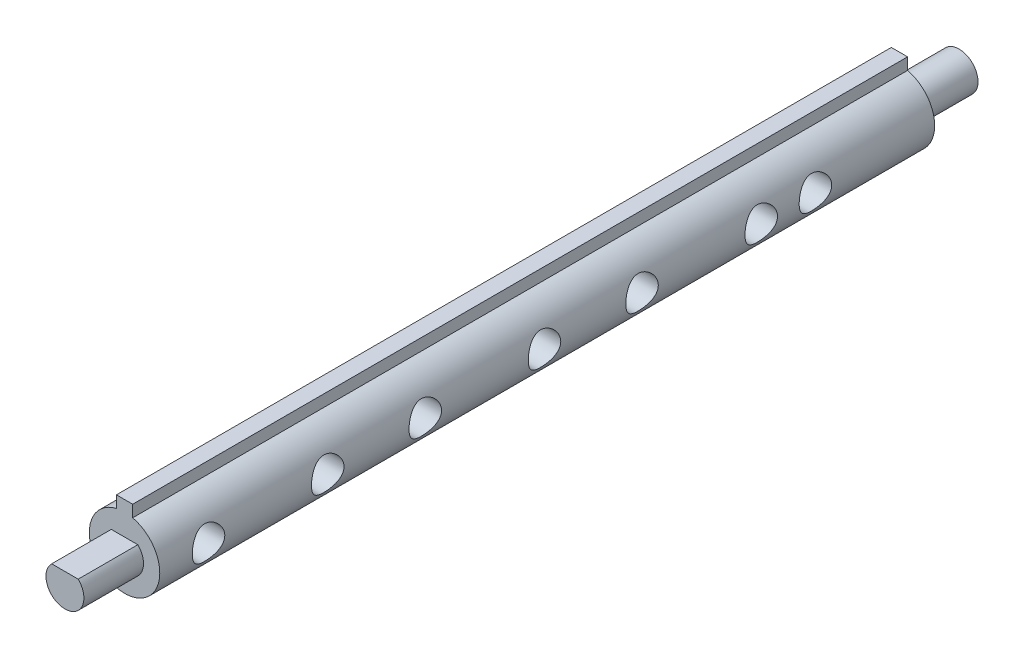
from build123d import *

# Parameters (mm, degrees)
EXTRUDE_1_DEPTH     = 143
SKETCH_2_R          = 3.5
EXTRUDE_2_DEPTH     = 11
SKETCH_3_R          = 3.5
EXTRUDE_3_DEPTH     = 11
CUT_EXTRUDE_1_DEPTH = 11
CUT_EXTRUDE_2_DEPTH = 11
SKETCH_7_R          = 3
CUT_EXTRUDE_3_DEPTH = 10


with BuildPart() as part:
    # 草图1 → 凸台-拉伸1 (new body)
    with BuildSketch(Plane.XY):
        with BuildLine():
            Line((-1.5, 6.32455532), (-1.5, 8.5))
            Line((-1.5, 8.5), (1.5, 8.5))
            Line((1.5, 8.5), (1.5, 6.32455532))
            ThreePointArc((1.5, 6.32455532), (0, -6.5), (-1.5, 6.32455532))
        make_face()
    extrude(amount=EXTRUDE_1_DEPTH)

    # 草图2 → 凸台-拉伸2 (add)
    with BuildSketch(Plane.XY.offset(143)):
        Circle(SKETCH_2_R)
    extrude(amount=EXTRUDE_2_DEPTH)

    # 草图3 → 凸台-拉伸3 (add)
    with BuildSketch(Plane(origin=(0, 0, 0), x_dir=(-1, 0, 0), z_dir=(0, 0, -1))):
        Circle(SKETCH_3_R)
    extrude(amount=EXTRUDE_3_DEPTH)

    # 草图4 → 切除-拉伸1 (cut)
    with BuildSketch(Plane(origin=(0, 0, -11), x_dir=(-1, 0, 0), z_dir=(0, 0, -1))):
        with BuildLine():
            Line((-2.449489743, -2.5), (2.449489743, -2.5))
            ThreePointArc((2.449489743, -2.5), (0, -3.5), (-2.449489743, -2.5))
        make_face()
    extrude(amount=-CUT_EXTRUDE_1_DEPTH, mode=Mode.SUBTRACT)

    # 草图5 → 切除-拉伸2 (cut)
    with BuildSketch(Plane.XY.offset(154)):
        with BuildLine():
            Line((-2.449489743, 2.5), (2.449489743, 2.5))
            ThreePointArc((2.449489743, 2.5), (0, 3.5), (-2.449489743, 2.5))
        make_face()
    extrude(amount=-CUT_EXTRUDE_2_DEPTH, mode=Mode.SUBTRACT)

    # 草图7 → 切除-拉伸3 (cut, symmetric)
    with BuildSketch(Plane(origin=(0, 0, 0), x_dir=(0, 0, -1), z_dir=(1, 0, 0))):
        with Locations((-134, 0)):
            Circle(SKETCH_7_R)
        with Locations((-112, 0)):
            Circle(SKETCH_7_R)
        with Locations((-94, 0)):
            Circle(SKETCH_7_R)
        with Locations((-72, 0)):
            Circle(SKETCH_7_R)
        with Locations((-54, 0)):
            Circle(SKETCH_7_R)
        with Locations((-32, 0)):
            Circle(SKETCH_7_R)
        with Locations((-22, 0)):
            Circle(SKETCH_7_R)
    extrude(amount=CUT_EXTRUDE_3_DEPTH, both=True, mode=Mode.SUBTRACT)


solid = part.part
